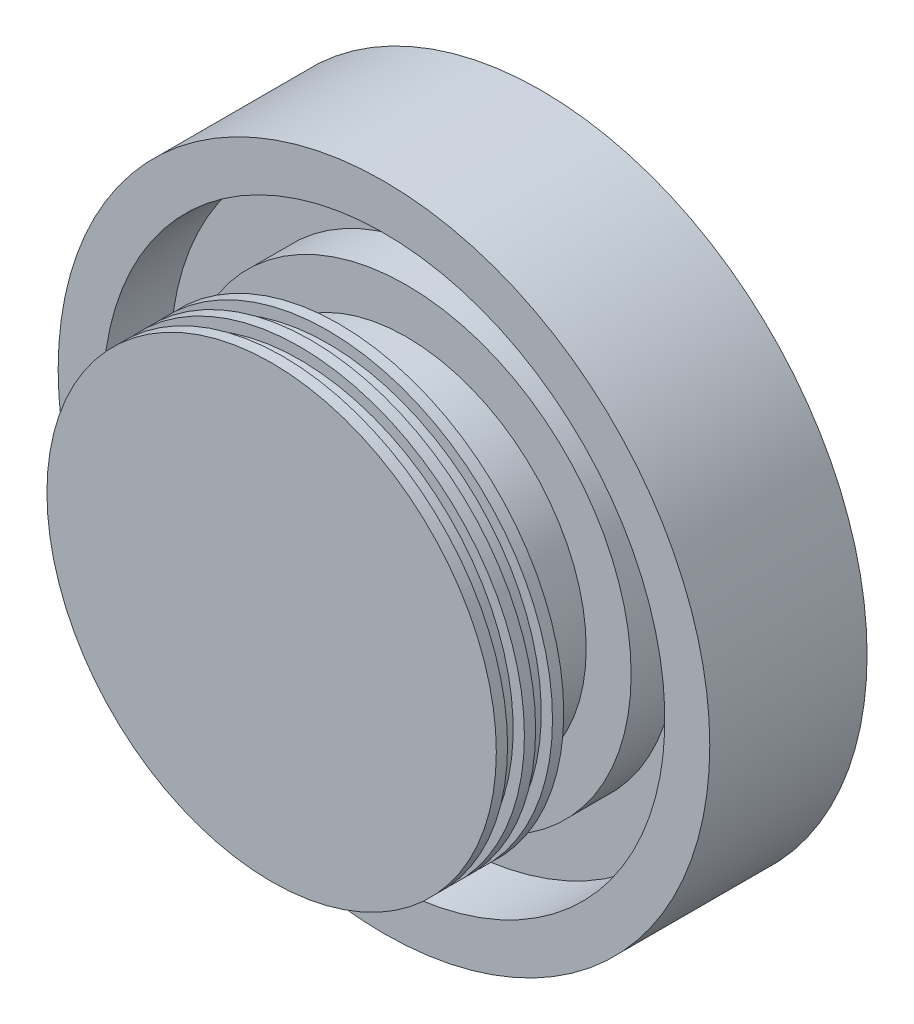
from build123d import *


with BuildPart() as part:
    # Sketch1 → Revolve1 (revolve)
    with BuildSketch(Plane(origin=(0, 0, 0), x_dir=(1, 0, 0), z_dir=(0, 1, 0))):
        Polygon((0, 44.45), (0, 0), (63.5, 0), (63.5, 3.175), (60.325, 3.175), (60.325, 7.9375), (63.5, 7.9375), (63.5, 11.1125), (60.325, 11.1125), (60.325, 15.875), (63.5, 15.875), (63.5, 19.05), (50.8, 19.05), (50.8, 38.1), (63.5, 38.1), (63.5, 50.8), (79.375, 50.8), (79.375, 31.75), (92.075, 31.75), (92.075, 76.2), (12.7, 76.2), (12.7, 63.5), (38.1, 63.5), (38.1, 44.45), align=None)
    revolve(axis=Axis((0, 0, -44.45), (0, 0, 1)))


solid = part.part
